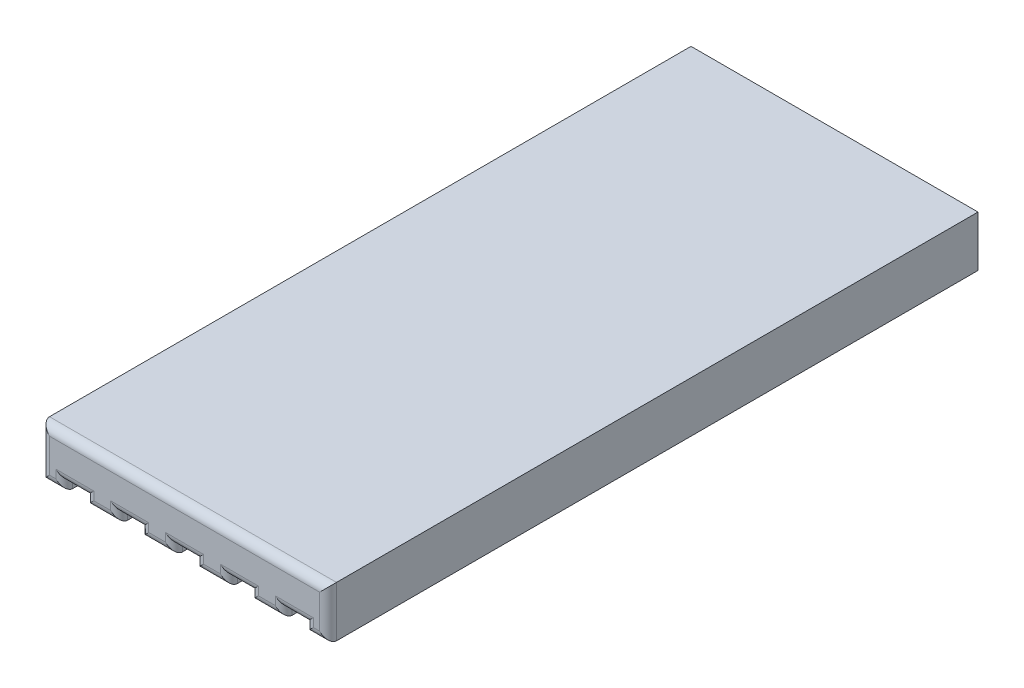
from build123d import *

# Parameters (mm, degrees)
SKETCH2_W                = 3.4
SKETCH2_H                = 0.6
BOSS_EXTRUDE2_DEPTH      = 2.7
BOSS_EXTRUDE2_DEPTH_BACK = 5
SKETCH3_W                = 0.25
SKETCH3_H                = 0.1
CUT_EXTRUDE1_DEPTH       = 3
FILLET1_R                = 0.1


with BuildPart() as part:
    # Sketch2 → Boss-Extrude2 (new body, two sides)
    with BuildSketch(Plane.XY.offset(-3.5)) as boss_extrude2_sk:
        with Locations((0, 1.5)):
            Rectangle(SKETCH2_W, SKETCH2_H)
    extrude(amount=BOSS_EXTRUDE2_DEPTH)
    extrude(boss_extrude2_sk.sketch, amount=-BOSS_EXTRUDE2_DEPTH_BACK)

    # Sketch3 → Cut-Extrude1 (cut)
    with BuildSketch(Plane.XY.offset(-0.8)):
        with Locations((-1.3, 1.25)):
            Rectangle(SKETCH3_W, SKETCH3_H)
        with Locations((-0.65, 1.25)):
            Rectangle(SKETCH3_W, SKETCH3_H)
        with Locations((0, 1.25)):
            Rectangle(SKETCH3_W, SKETCH3_H)
        with Locations((0.65, 1.25)):
            Rectangle(SKETCH3_W, SKETCH3_H)
        with Locations((1.3, 1.25)):
            Rectangle(SKETCH3_W, SKETCH3_H)
    extrude(amount=-CUT_EXTRUDE1_DEPTH, mode=Mode.SUBTRACT)

    # Fillet1
    fillet1_edges = [part.edges().sort_by_distance(p)[0] for p in [
        (0, 1.8, -0.8),
        (1.7, 1.5, -0.8),
        (1.5625, 1.2, -0.8),
        (-1.5625, 1.2, -0.8),
        (-1.7, 1.5, -0.8),
        (0.975, 1.2, -0.8),
        (0.775, 1.25, -0.8),
        (0.65, 1.3, -0.8),
        (0.525, 1.25, -0.8),
        (0.325, 1.2, -0.8),
        (0.125, 1.25, -0.8),
        (0, 1.3, -0.8),
        (-0.125, 1.25, -0.8),
        (-0.325, 1.2, -0.8),
        (-0.525, 1.25, -0.8),
        (-0.65, 1.3, -0.8),
        (-0.775, 1.25, -0.8),
        (-0.975, 1.2, -0.8),
        (-1.175, 1.25, -0.8),
        (-1.3, 1.3, -0.8),
        (-1.425, 1.25, -0.8),
        (1.425, 1.25, -0.8),
        (1.3, 1.3, -0.8),
        (1.175, 1.25, -0.8),
    ]]
    fillet(fillet1_edges, radius=FILLET1_R)


solid = part.part
